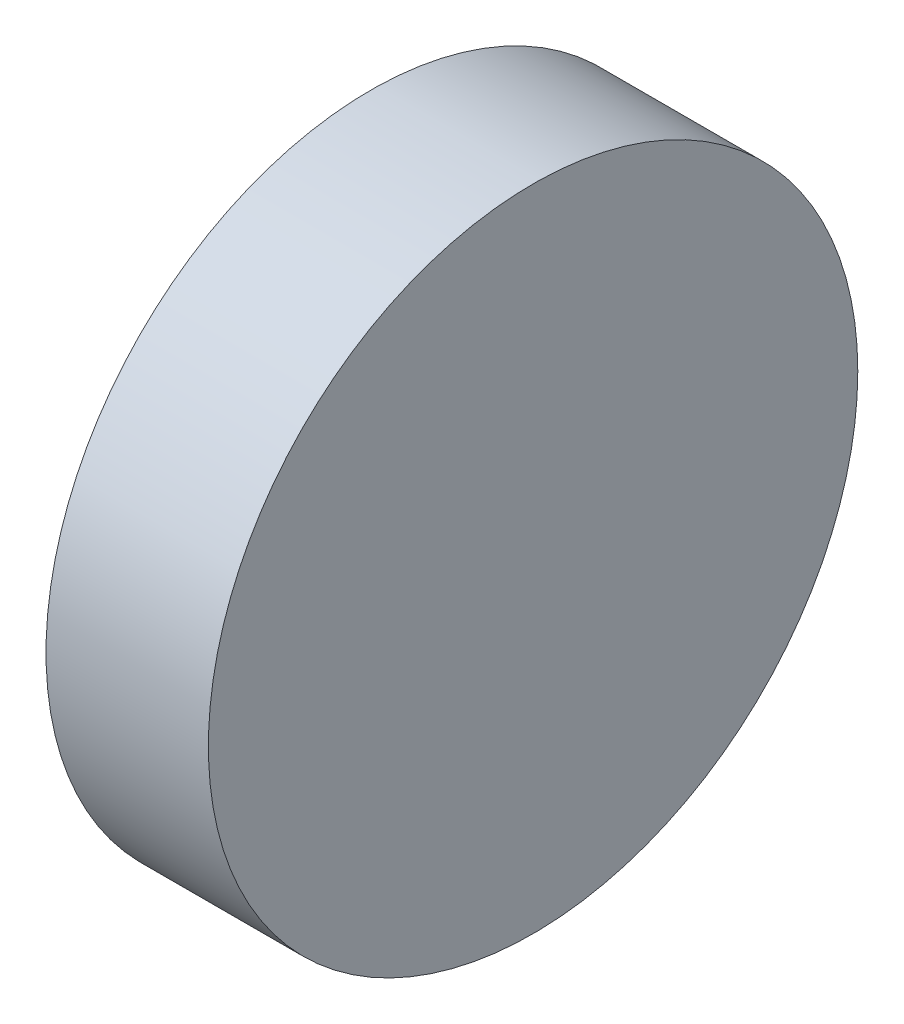
from build123d import *

# Parameters (mm, degrees)
SKETCH2_R      = 600
EXTRUDE1_DEPTH = 300


with BuildPart() as part:
    # Sketch2 → Extrude1 (new body)
    with BuildSketch(Plane(origin=(3109.4197493, 0, 0), x_dir=(0, 0, -1), z_dir=(1, 0, 0))):
        with Locations((50.339261683, -50.554392858)):
            Circle(SKETCH2_R)
    extrude(amount=EXTRUDE1_DEPTH)


solid = part.part
